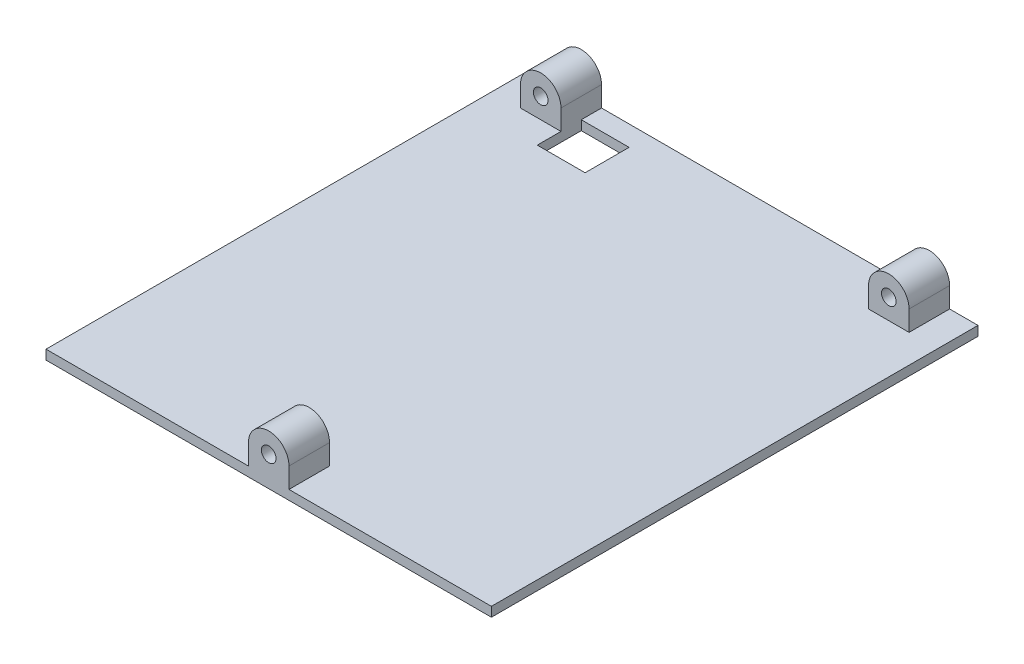
from build123d import *

# Parameters (mm, degrees)
SKETCH1_W           = 139.5
SKETCH1_H           = 152.4
BOSS_EXTRUDE1_DEPTH = 6.35
SKETCH2_W           = 139.5
SKETCH2_H           = 152.4
CUT_EXTRUDE1_DEPTH  = 3.375
SKETCH3_R           = 2.286
BOSS_EXTRUDE2_DEPTH = 12.7
SKETCH4_R           = 2.286
BOSS_EXTRUDE3_DEPTH = 12.7
SKETCH5_W           = 14.986
SKETCH5_H           = 13.7795
CUT_EXTRUDE2_DEPTH  = 3.975


with BuildPart() as part:
    # Sketch1 → Boss-Extrude1 (new body)
    with BuildSketch(Plane(origin=(0, 0, 0), x_dir=(1, 0, 0), z_dir=(0, 1, 0))):
        with Locations((69.75, 76.2)):
            Rectangle(SKETCH1_W, SKETCH1_H)
    extrude(amount=BOSS_EXTRUDE1_DEPTH)

    # Sketch2 → Cut-Extrude1 (cut)
    with BuildSketch(Plane(origin=(0, 6.35, 0), x_dir=(1, 0, 0), z_dir=(0, 1, 0))):
        with Locations((69.75, 76.2)):
            Rectangle(SKETCH2_W, SKETCH2_H)
    extrude(amount=-CUT_EXTRUDE1_DEPTH, mode=Mode.SUBTRACT)

    # Sketch3 → Boss-Extrude2 (add)
    with BuildSketch(Plane.XY):
        with BuildLine():
            Line((63.4, 9.325), (63.4, 2.975))
            Line((63.4, 2.975), (76.1, 2.975))
            Line((76.1, 2.975), (76.1, 9.325000158))
            ThreePointArc((76.1, 9.325000158), (69.749999921, 15.675000158), (63.4, 9.325))
        make_face()
        with Locations((69.75, 9.325000158)):
            Circle(SKETCH3_R, mode=Mode.SUBTRACT)
    extrude(amount=-BOSS_EXTRUDE2_DEPTH)

    # Sketch4 → Boss-Extrude3 (add)
    with BuildSketch(Plane(origin=(0, 0, -152.4), x_dir=(-1, 0, 0), z_dir=(0, 0, -1))):
        with BuildLine():
            Line((-130.61, 9.325), (-130.61, 2.975))
            Line((-130.61, 2.975), (-117.91, 2.975))
            Line((-117.91, 2.975), (-117.91, 9.325))
            ThreePointArc((-117.91, 9.325), (-124.26, 15.675), (-130.61, 9.325))
        make_face()
        with Locations((-124.26, 9.325)):
            Circle(SKETCH4_R, mode=Mode.SUBTRACT)
        with BuildLine():
            Line((-21.59, 9.325), (-21.59, 2.975))
            Line((-21.59, 2.975), (-8.89, 2.975))
            Line((-8.89, 2.975), (-8.89, 9.325))
            ThreePointArc((-8.89, 9.325), (-15.24, 15.675), (-21.59, 9.325))
        make_face()
        with Locations((-15.24, 9.325)):
            Circle(SKETCH4_R, mode=Mode.SUBTRACT)
    extrude(amount=-BOSS_EXTRUDE3_DEPTH)

    # Sketch5 → Cut-Extrude2 (cut, through all)
    with BuildSketch(Plane(origin=(0, 2.975, 0), x_dir=(1, 0, 0), z_dir=(0, 1, 0))):
        with Locations((29.083, 139.16025)):
            Rectangle(SKETCH5_W, SKETCH5_H)
    extrude(amount=-CUT_EXTRUDE2_DEPTH, mode=Mode.SUBTRACT)


solid = part.part
